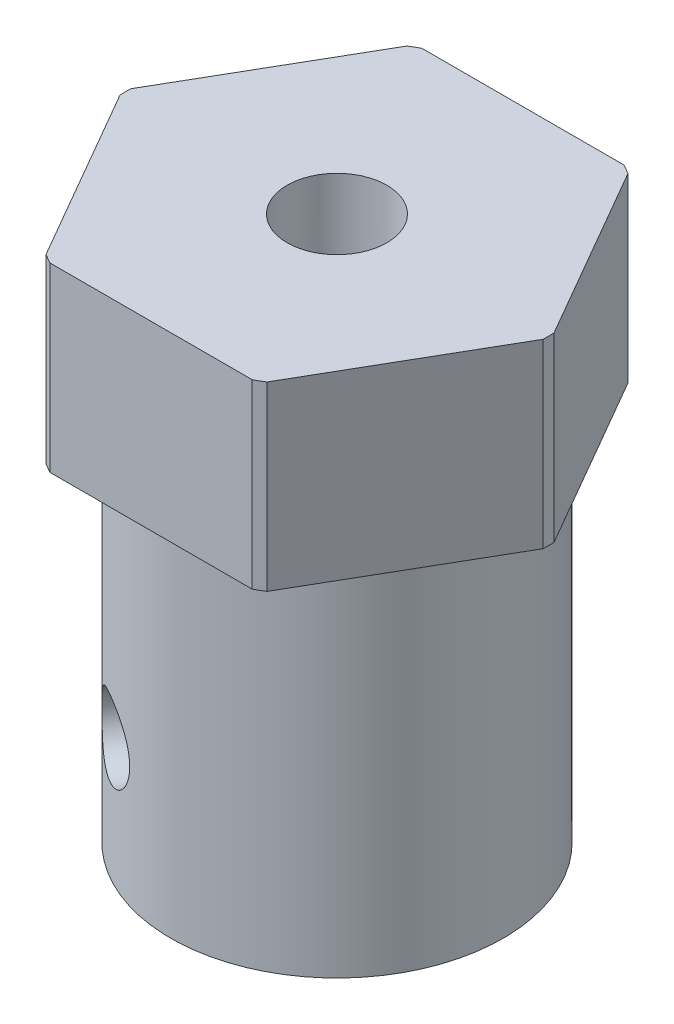
from build123d import *

# Parameters (mm, degrees)
SKETCH_2_OUTSIDE_W  = 21.352
SKETCH_2_OUTSIDE_H  = 21.352
CUT_EXTRUDE_1_DEPTH = 19
HOLE_WIZARD_M4_1_D  = 3.3
SKETCH_5_R          = 3
CUT_EXTRUDE_2_DEPTH = 14
HOLE_WIZARD_M3_1_D  = 2.5


with BuildPart() as part:
    # 草图1 → 旋转1 (revolve)
    with BuildSketch(Plane.XY):
        Polygon((0, 0), (0, 18), (7, 18), (7, 12), (5.5, 12), (5.5, 0), align=None)
    revolve(axis=Axis((0, 0, 0), (0, 1, 0)))

    # 草图2 outside → 切除-拉伸1 (cut, through all)
    with BuildSketch(Plane(origin=(0, 18, 0), x_dir=(1, 0, 0), z_dir=(0, 1, 0))):
        Rectangle(SKETCH_2_OUTSIDE_W, SKETCH_2_OUTSIDE_H)
        Polygon((7.101408311, 0), (3.550704156, 6.15), (-3.550704156, 6.15), (-7.101408311, 0), (-3.550704156, -6.15), (3.550704156, -6.15), align=None, mode=Mode.SUBTRACT)
    extrude(amount=-CUT_EXTRUDE_1_DEPTH, mode=Mode.SUBTRACT)

    # M4 螺纹孔1 (through all)
    with Locations(Plane(origin=(0, 18, 0), x_dir=(1, 0, 0), z_dir=(0, 1, 0))):
        with Locations((0, 0)):
            Hole(HOLE_WIZARD_M4_1_D / 2)

    # 草图5 → 切除-拉伸2 (cut)
    with BuildSketch(Plane.XZ):
        Circle(SKETCH_5_R)
    extrude(amount=-CUT_EXTRUDE_2_DEPTH, mode=Mode.SUBTRACT)

    # M3 螺纹孔1 (through all)
    with Locations(Plane(origin=(-2.75, 0, 4.763139721), x_dir=(-0.866025404, 0, -0.5), z_dir=(-0.5, 0, 0.866025404))):
        with Locations((0, -4)):
            Hole(HOLE_WIZARD_M3_1_D / 2)


solid = part.part
